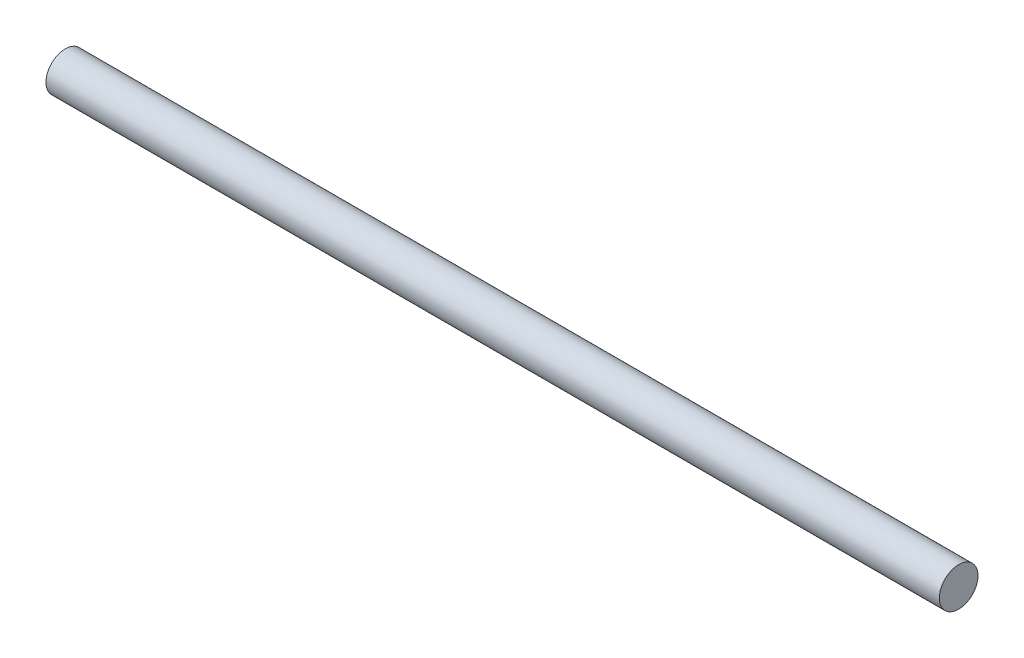
from build123d import *

# Parameters (mm, degrees)
BARRER1_PROFILE_R = 5


with BuildPart() as part:
    # Barrer1: sweep along a path in Croquis1
    with BuildLine(Plane.XY) as barrer1_path:
        Line((0, 0), (231, 0))
    # Barrer1 profile (on start of the path) → Barrer1 (sweep)
    with BuildSketch(Plane(origin=(0, 0, 0), x_dir=(0, 0, 1), z_dir=(1, 0, 0))):
        Circle(BARRER1_PROFILE_R)
    sweep(path=barrer1_path.line)


solid = part.part
